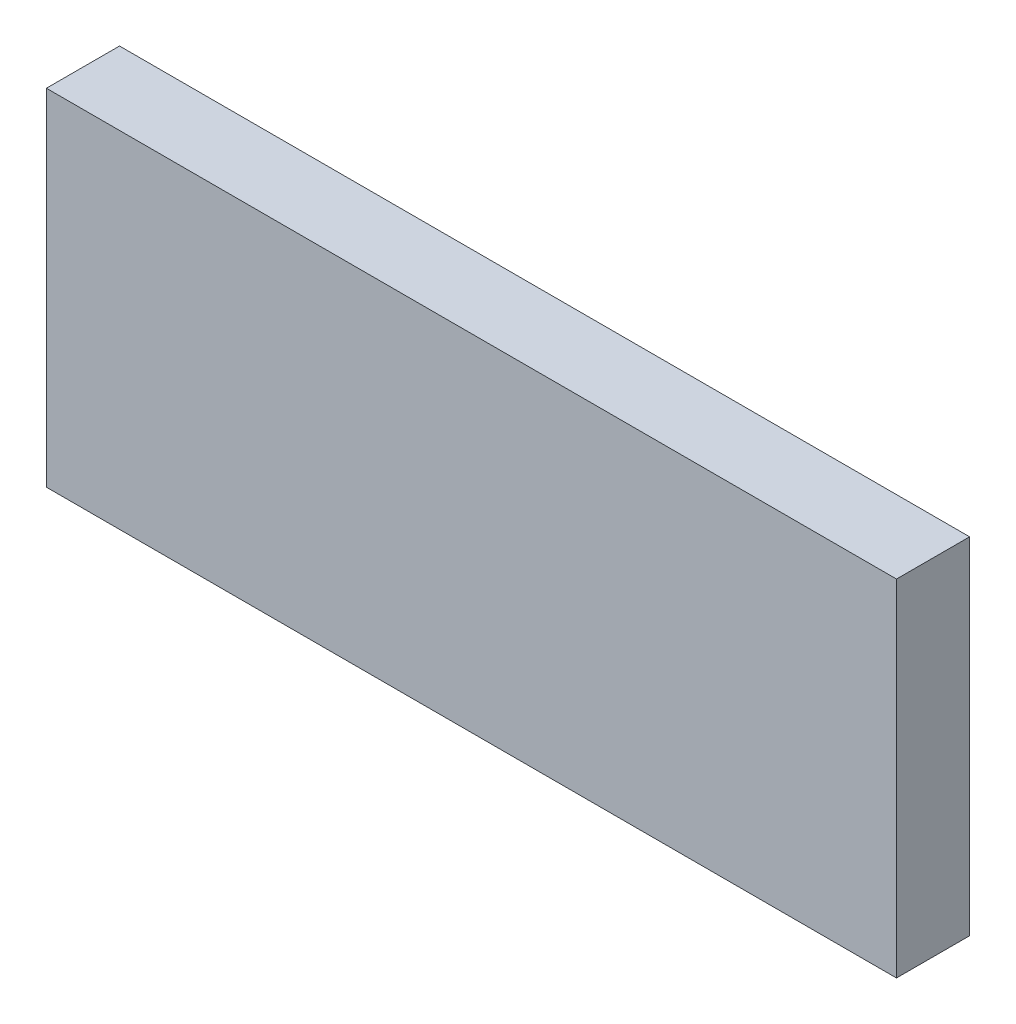
from build123d import *

# Parameters (mm, degrees)
ESQUISSE1_W        = 93
ESQUISSE1_H        = 37.8
BOSS_EXTRU_1_DEPTH = 8


with BuildPart() as part:
    # Esquisse1 → Boss.-Extru.1 (new body)
    with BuildSketch(Plane.XY):
        with Locations((-46.5, 18.9)):
            Rectangle(ESQUISSE1_W, ESQUISSE1_H)
    extrude(amount=BOSS_EXTRU_1_DEPTH)


solid = part.part
